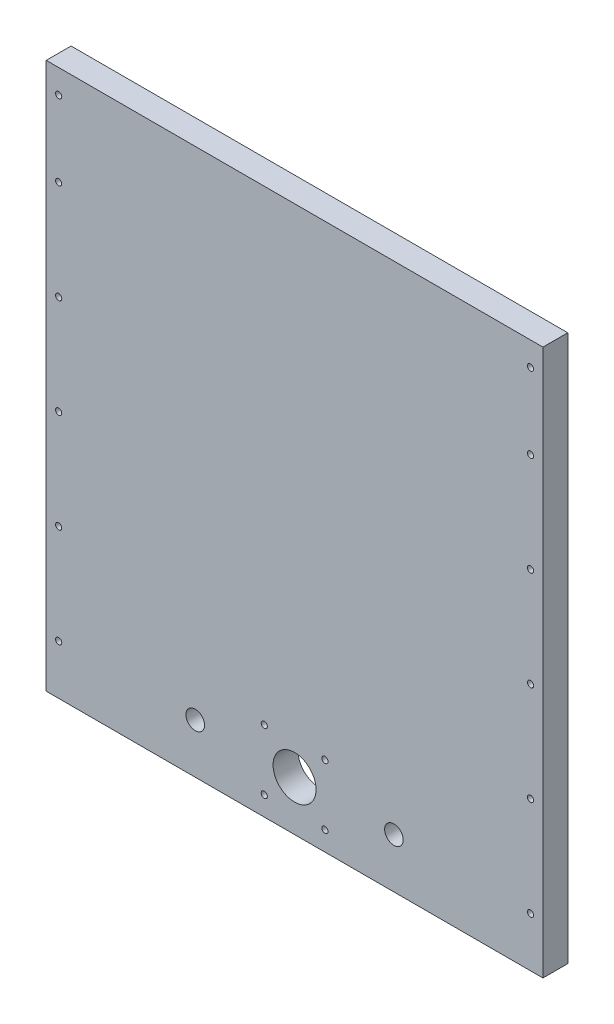
from build123d import *

# Parameters (mm, degrees)
SKETCH1_W           = 254
SKETCH1_H           = 279.4
SKETCH1_R           = 1.5875
SKETCH1_R_2         = 4.7625
SKETCH1_R_3         = 11
BOSS_EXTRUDE1_DEPTH = 12.7


with BuildPart() as part:
    # Sketch1 → Boss-Extrude1 (new body)
    with BuildSketch(Plane.XY):
        with Locations((127, 139.7)):
            Rectangle(SKETCH1_W, SKETCH1_H)
        with Locations((6.35, 25.4)):
            Circle(SKETCH1_R, mode=Mode.SUBTRACT)
        with Locations((247.65, 25.4)):
            Circle(SKETCH1_R, mode=Mode.SUBTRACT)
        with Locations((6.35, 76.2)):
            Circle(SKETCH1_R, mode=Mode.SUBTRACT)
        with Locations((247.65, 76.2)):
            Circle(SKETCH1_R, mode=Mode.SUBTRACT)
        with Locations((6.35, 127)):
            Circle(SKETCH1_R, mode=Mode.SUBTRACT)
        with Locations((247.65, 127)):
            Circle(SKETCH1_R, mode=Mode.SUBTRACT)
        with Locations((6.35, 177.8)):
            Circle(SKETCH1_R, mode=Mode.SUBTRACT)
        with Locations((247.65, 177.8)):
            Circle(SKETCH1_R, mode=Mode.SUBTRACT)
        with Locations((76.2, 25.4)):
            Circle(SKETCH1_R_2, mode=Mode.SUBTRACT)
        with Locations((177.8, 25.4)):
            Circle(SKETCH1_R_2, mode=Mode.SUBTRACT)
        with Locations((127, 25.4)):
            Circle(SKETCH1_R_3, mode=Mode.SUBTRACT)
        with Locations((142.499999988, 40.899999988)):
            Circle(SKETCH1_R, mode=Mode.SUBTRACT)
        with Locations((111.511999988, 40.899999988)):
            Circle(SKETCH1_R, mode=Mode.SUBTRACT)
        with Locations((142.499999988, 9.911999988)):
            Circle(SKETCH1_R, mode=Mode.SUBTRACT)
        with Locations((111.511999988, 9.911999988)):
            Circle(SKETCH1_R, mode=Mode.SUBTRACT)
        with Locations((6.35, 228.6)):
            Circle(SKETCH1_R, mode=Mode.SUBTRACT)
        with Locations((247.65, 228.6)):
            Circle(SKETCH1_R, mode=Mode.SUBTRACT)
        with Locations((6.35, 267.208)):
            Circle(SKETCH1_R, mode=Mode.SUBTRACT)
        with Locations((247.65, 267.208)):
            Circle(SKETCH1_R, mode=Mode.SUBTRACT)
    extrude(amount=BOSS_EXTRUDE1_DEPTH)


solid = part.part
